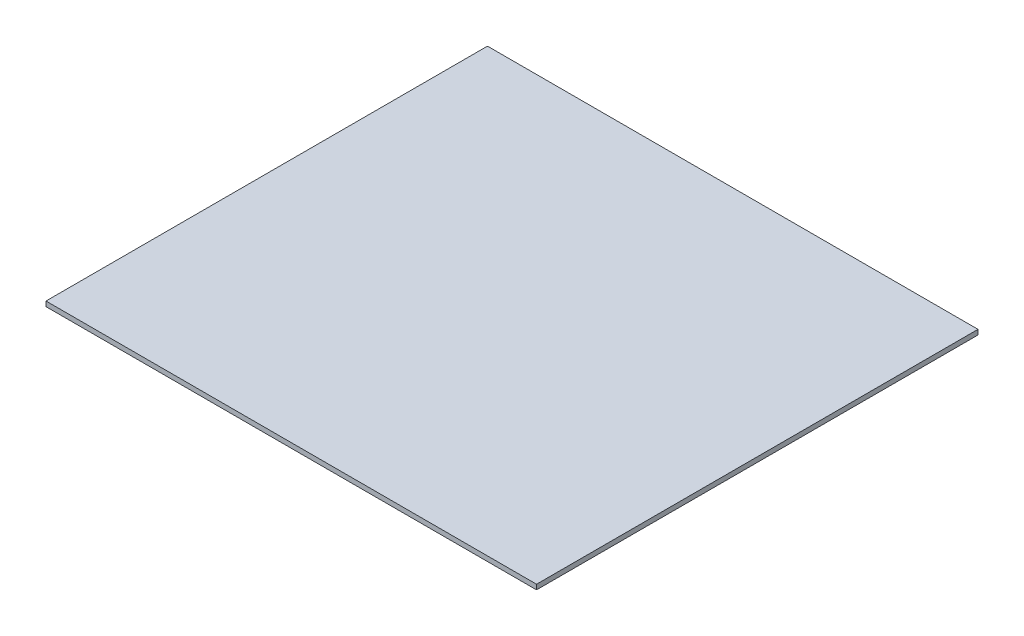
from build123d import *

# Parameters (mm, degrees)
SKETCH1_W           = 1000
SKETCH1_H           = 900
BOSS_EXTRUDE1_DEPTH = 10


with BuildPart() as part:
    # Sketch1 → Boss-Extrude1 (new body)
    with BuildSketch(Plane(origin=(0, 0, 0), x_dir=(1, 0, 0), z_dir=(0, 1, 0))):
        Rectangle(SKETCH1_W, SKETCH1_H)
    extrude(amount=BOSS_EXTRUDE1_DEPTH)


solid = part.part
